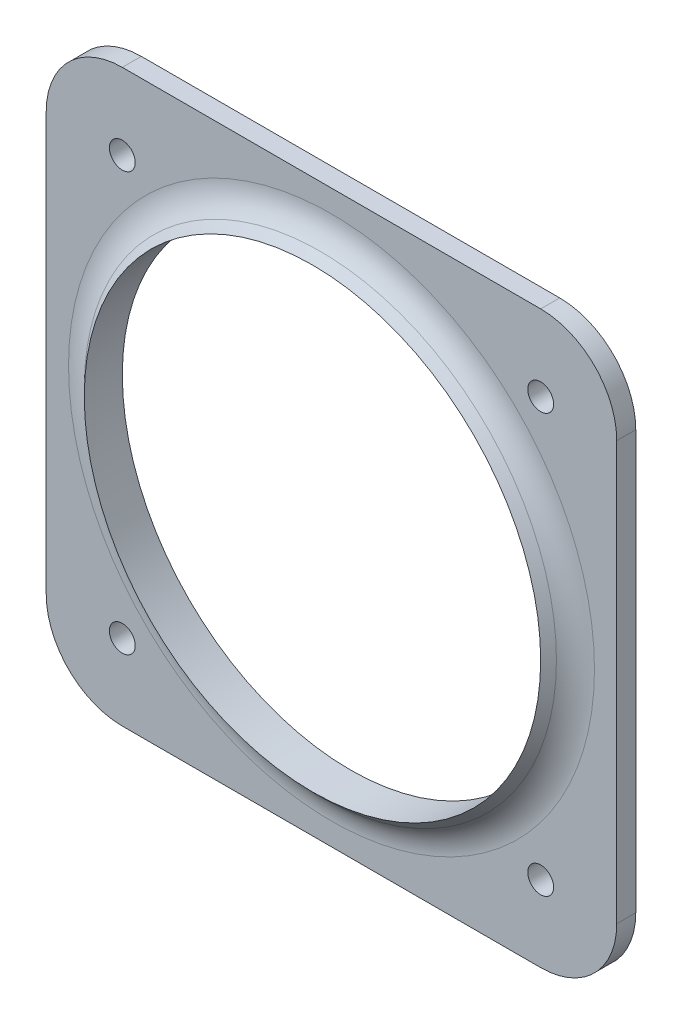
from build123d import *

# Parameters (mm, degrees)
SKETCH1_W           = 95.25
SKETCH1_H           = 95.25
SKETCH1_R           = 38.1
BOSS_EXTRUDE1_DEPTH = 3.175
FILLET1_R           = 6.35
SKETCH4_R           = 2.159
CUT_EXTRUDE1_DEPTH  = 4.175
FILLET2_R           = 12.7


with BuildPart() as part:
    # Sketch1 → Boss-Extrude1 (new body)
    with BuildSketch(Plane.XY):
        Rectangle(SKETCH1_W, SKETCH1_H)
        Circle(SKETCH1_R, mode=Mode.SUBTRACT)
    extrude(amount=BOSS_EXTRUDE1_DEPTH)

    # Sketch2 → Revolve1 (revolve)
    with BuildSketch(Plane(origin=(0, 0, 0), x_dir=(1, 0, 0), z_dir=(0, 1, 0))):
        Polygon((38.1, -3.175), (38.1, -6.35), (41.275, -3.175), align=None)
    revolve(axis=Axis((0, 0, 1000), (0, 0, -1)))

    # Fillet1
    fillet1_edges = [part.edges().sort_by_distance(p)[0] for p in [
        (-41.275, 0, 3.175),
    ]]
    fillet(fillet1_edges, radius=FILLET1_R)

    # Sketch4 → Cut-Extrude1 (cut, through all)
    with BuildSketch(Plane.XY.offset(3.175)):
        with Locations((-34.925, 34.925)):
            Circle(SKETCH4_R)
        with Locations((34.925, 34.925)):
            Circle(SKETCH4_R)
        with Locations((34.925, -34.925)):
            Circle(SKETCH4_R)
        with Locations((-34.925, -34.925)):
            Circle(SKETCH4_R)
    extrude(amount=-CUT_EXTRUDE1_DEPTH, mode=Mode.SUBTRACT)

    # Fillet2
    fillet2_edges = [part.edges().sort_by_distance(p)[0] for p in [
        (-47.625, 47.625, 1.5875),
        (47.625, 47.625, 1.5875),
        (47.625, -47.625, 1.5875),
        (-47.625, -47.625, 1.5875),
    ]]
    fillet(fillet2_edges, radius=FILLET2_R)


solid = part.part
